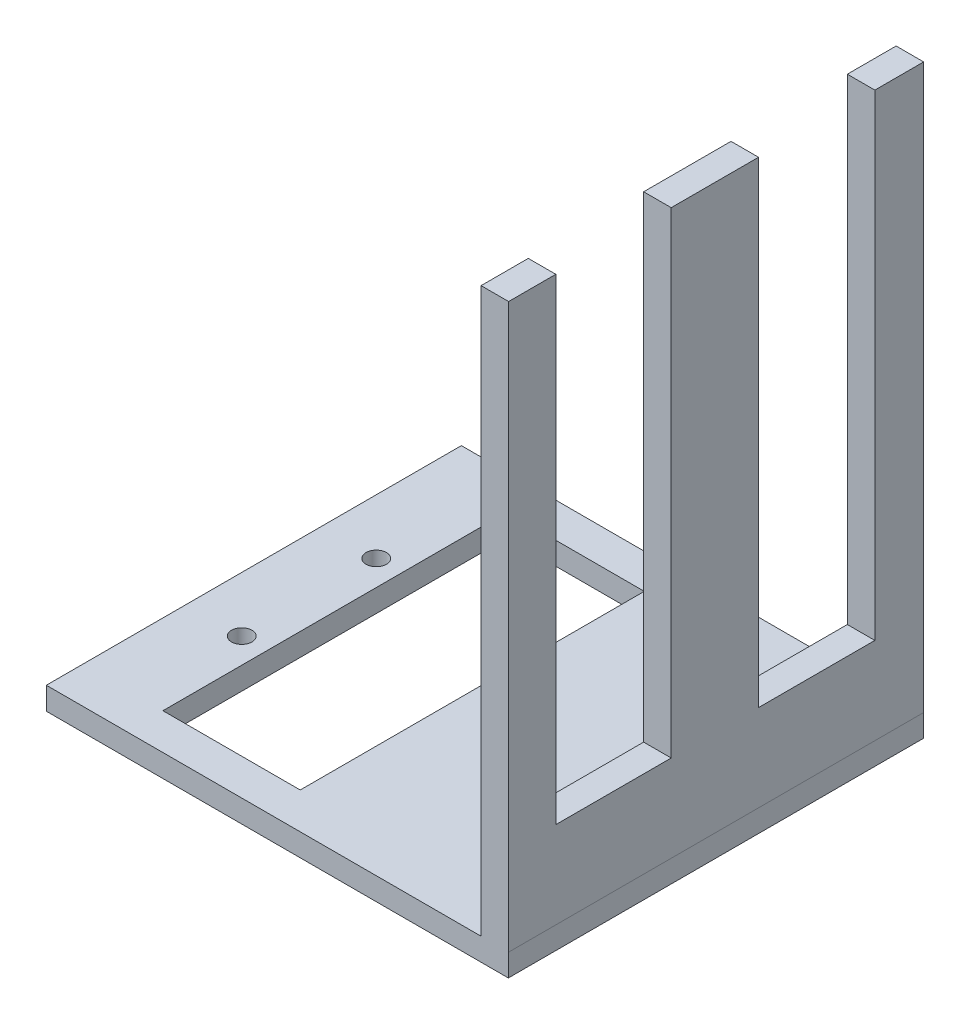
from build123d import *

# Parameters (mm, degrees)
SKETCH1_W           = 82
SKETCH1_H           = 73.66
BOSS_EXTRUDE1_DEPTH = 4
SKETCH2_W           = 4.88717895
SKETCH2_H           = 73.66
BOSS_EXTRUDE2_DEPTH = 100
SKETCH3_R           = 1.8125
CUT_EXTRUDE1_DEPTH  = 10
SKETCH4_W           = 24.37
SKETCH4_H           = 61.062715067
CUT_EXTRUDE2_DEPTH  = 10
SKETCH5_W           = 20.642645576
SKETCH5_H           = 101.129835632
SKETCH5_W_2         = 20.479187661
SKETCH5_H_2         = 100.180376076
CUT_EXTRUDE3_DEPTH  = 10


with BuildPart() as part:
    # Sketch1 → Boss-Extrude1 (new body)
    with BuildSketch(Plane(origin=(0, 0, 0), x_dir=(1, 0, 0), z_dir=(0, 1, 0))):
        with Locations((0.667646454, -2.157941762)):
            Rectangle(SKETCH1_W, SKETCH1_H)
    extrude(amount=BOSS_EXTRUDE1_DEPTH)

    # Sketch2 → Boss-Extrude2 (add)
    with BuildSketch(Plane(origin=(0, 4, 0), x_dir=(1, 0, 0), z_dir=(0, 1, 0))):
        with Locations((39.271911138, -2.157941762)):
            Rectangle(SKETCH2_W, SKETCH2_H)
    extrude(amount=BOSS_EXTRUDE2_DEPTH)

    # Sketch3 → Cut-Extrude1 (cut)
    with BuildSketch(Plane(origin=(0, 4, 0), x_dir=(1, 0, 0), z_dir=(0, 1, 0))):
        with Locations((-30.544050148, 9.782058238)):
            Circle(SKETCH3_R)
        with Locations((-30.544050148, -14.097941762)):
            Circle(SKETCH3_R)
    extrude(amount=-CUT_EXTRUDE1_DEPTH, mode=Mode.SUBTRACT)

    # Sketch4 → Cut-Extrude2 (cut)
    with BuildSketch(Plane(origin=(0, 4, 0), x_dir=(1, 0, 0), z_dir=(0, 1, 0))):
        with Locations((-13.885112628, -2.028636366)):
            Rectangle(SKETCH4_W, SKETCH4_H)
    extrude(amount=-CUT_EXTRUDE2_DEPTH, mode=Mode.SUBTRACT)

    # Sketch5 → Cut-Extrude3 (cut)
    with BuildSketch(Plane(origin=(41.715500613, 0, 0), x_dir=(0, 0, -1), z_dir=(1, 0, 0))):
        with Locations((15.687392669, 69.976580633)):
            Rectangle(SKETCH5_W, SKETCH5_H)
        with Locations((-20.375345347, 69.501850855)):
            Rectangle(SKETCH5_W_2, SKETCH5_H_2)
    extrude(amount=-CUT_EXTRUDE3_DEPTH, mode=Mode.SUBTRACT)


solid = part.part
